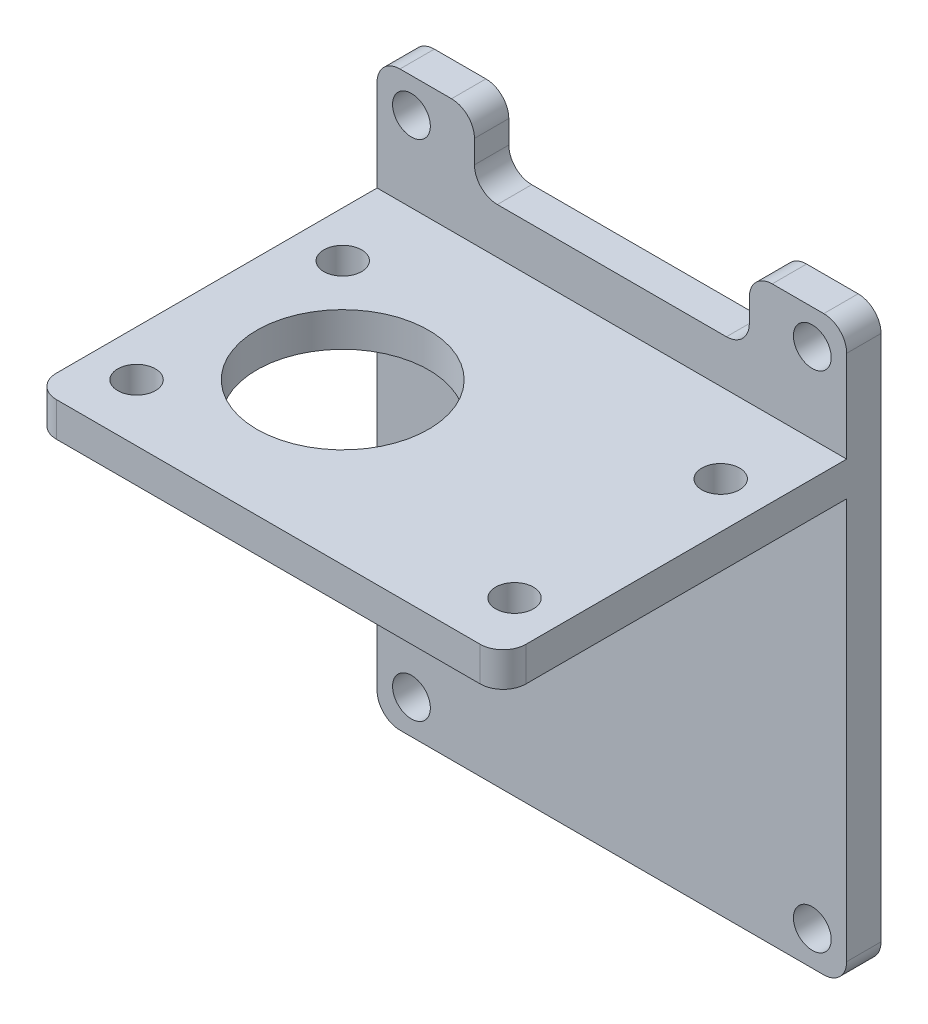
from build123d import *

# Parameters (mm, degrees)
SKETCH1_W           = 41
SKETCH1_H           = 50
SKETCH1_R           = 1.65
BOSS_EXTRUDE1_DEPTH = 3
SKETCH2_W           = 41
SKETCH2_H           = 3
BOSS_EXTRUDE2_DEPTH = 30
SKETCH3_R           = 1.65
SKETCH3_R_2         = 7.5
CUT_EXTRUDE1_DEPTH  = 35
SKETCH4_W           = 24
SKETCH4_H           = 6
CUT_EXTRUDE2_DEPTH  = 10
FILLET2_R           = 2


with BuildPart() as part:
    # Sketch1 → Boss-Extrude1 (new body)
    with BuildSketch(Plane.XY):
        with Locations((17.5, 22)):
            Rectangle(SKETCH1_W, SKETCH1_H)
        with Locations((0, 44)):
            Circle(SKETCH1_R, mode=Mode.SUBTRACT)
        with Locations((35, 44)):
            Circle(SKETCH1_R, mode=Mode.SUBTRACT)
        with Locations((35, 0)):
            Circle(SKETCH1_R, mode=Mode.SUBTRACT)
        Circle(SKETCH1_R, mode=Mode.SUBTRACT)
    extrude(amount=BOSS_EXTRUDE1_DEPTH)

    # Sketch2 → Boss-Extrude2 (add)
    with BuildSketch(Plane.XY.offset(3)):
        with Locations((17.5, 35.5)):
            Rectangle(SKETCH2_W, SKETCH2_H)
    extrude(amount=BOSS_EXTRUDE2_DEPTH)

    # Sketch3 → Cut-Extrude1 (cut)
    with BuildSketch(Plane(origin=(0, 37, 0), x_dir=(1, 0, 0), z_dir=(0, 1, 0))):
        with Locations((34, -28)):
            Circle(SKETCH3_R)
        with Locations((34, -10)):
            Circle(SKETCH3_R)
        with Locations((1, -10)):
            Circle(SKETCH3_R)
        with Locations((1, -28)):
            Circle(SKETCH3_R)
        with Locations((10, -19)):
            Circle(SKETCH3_R_2)
    extrude(amount=-CUT_EXTRUDE1_DEPTH, mode=Mode.SUBTRACT)

    # Sketch4 → Cut-Extrude2 (cut)
    with BuildSketch(Plane.XY.offset(3)):
        with Locations((17.5, 44)):
            Rectangle(SKETCH4_W, SKETCH4_H)
    extrude(amount=-CUT_EXTRUDE2_DEPTH, mode=Mode.SUBTRACT)

    # Fillet2
    fillet2_edges = [part.edges().sort_by_distance(p)[0] for p in [
        (-3, 35.5, 33),
        (38, 35.5, 33),
        (5.5, 47, 1.5),
        (29.5, 47, 1.5),
        (-3, 47, 1.5),
        (38, 47, 1.5),
        (29.5, 41, 1.5),
        (5.5, 41, 1.5),
        (38, -3, 1.5),
        (-3, -3, 1.5),
    ]]
    fillet(fillet2_edges, radius=FILLET2_R)


solid = part.part
